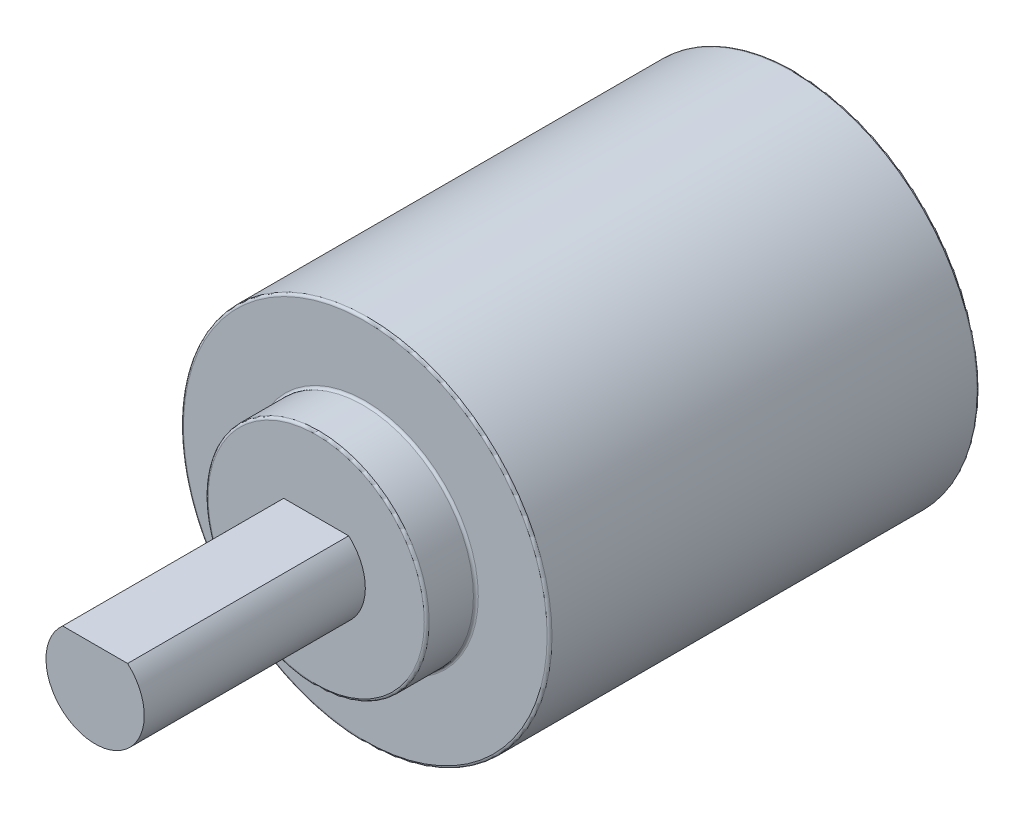
from build123d import *

# Parameters (mm, degrees)
ESQUISSE1_R             = 15
BOSS_EXTRU_1_DEPTH      = 35
ESQUISSE2_R             = 9
BOSS_EXTRU_2_DEPTH      = 4
BOSS_EXTRU_3_DEPTH      = 18
ESQUISSE4_R             = 10
ENL_V_MAT_EXTRU_1_DEPTH = 18
CONG_1_R                = 0.2
CONG_2_R                = 0.5


with BuildPart() as part:
    # Esquisse1 → Boss.-Extru.1 (new body)
    with BuildSketch(Plane.XY):
        Circle(ESQUISSE1_R)
    extrude(amount=BOSS_EXTRU_1_DEPTH)

    # Esquisse2 → Boss.-Extru.2 (add)
    with BuildSketch(Plane.XY.offset(35)):
        Circle(ESQUISSE2_R)
    extrude(amount=BOSS_EXTRU_2_DEPTH)

    # Esquisse3 → Boss.-Extru.3 (add)
    with BuildSketch(Plane.XY.offset(39)):
        with BuildLine():
            Line((2.645751311, 3), (-2.645751311, 3))
            ThreePointArc((-2.645751311, 3), (-1.645751311, -3.645751311), (4, 0))
            ThreePointArc((4, 0), (3.645751311, 1.645751311), (2.645751311, 3))
        make_face()
    extrude(amount=BOSS_EXTRU_3_DEPTH)

    # Esquisse4 → Enlèv. mat.-Extru.1 (cut)
    with BuildSketch(Plane(origin=(0, 0, 0), x_dir=(-1, 0, 0), z_dir=(0, 0, -1))):
        Circle(ESQUISSE4_R)
    extrude(amount=-ENL_V_MAT_EXTRU_1_DEPTH, mode=Mode.SUBTRACT)

    # Congé1
    cong_1_edges = [part.edges().sort_by_distance(p)[0] for p in [
        (-15, 0, 0),
        (10, 0, 0),
        (-15, 0, 35),
        (-9, 0, 35),
        (-9, 0, 39),
    ]]
    fillet(cong_1_edges, radius=CONG_1_R)

    # Congé2
    cong_2_edges = [part.edges().sort_by_distance(p)[0] for p in [
        (10, 0, 18),
    ]]
    fillet(cong_2_edges, radius=CONG_2_R)


solid = part.part
